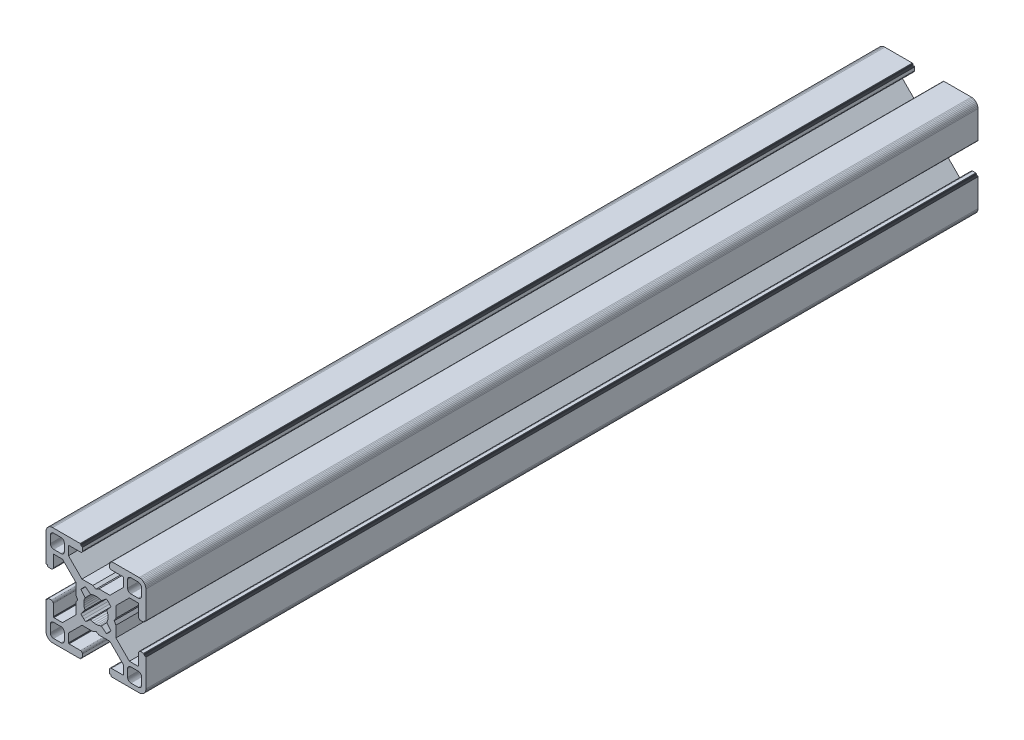
from build123d import *

# Parameters (mm, degrees)
BOSS_EXTRUDE1_DEPTH = 250


with BuildPart() as part:
    # Sketch1 → Boss-Extrude1 (new body)
    with BuildSketch(Plane.XY):
        Polygon((28.34729664, 29.969613999), (28.000000864, 29.999999329), (19.750000909, 29.999999329), (19.715268165, 29.996961355), (19.681595266, 29.987938702), (19.649999216, 29.973205179), (19.621443003, 29.953207821), (19.596790895, 29.928557575), (19.576793537, 29.899999499), (19.562061876, 29.868405312), (19.55303736, 29.834728688), (19.549999386, 29.799999669), (19.549999386, 29.699999839), (19.546961412, 29.665268958), (19.537936896, 29.631596059), (19.523203373, 29.599998146), (19.503207877, 29.571441934), (19.478557631, 29.546789825), (19.449999556, 29.526794329), (19.418403506, 29.512060806), (19.384728745, 29.503038153), (19.349999726, 29.500000179), (19.249999896, 29.500000179), (19.215267517, 29.496958527), (19.181592755, 29.487935874), (19.149996706, 29.47320235), (19.12143863, 29.453206855), (19.096788384, 29.428554746), (19.076791026, 29.399996671), (19.062057503, 29.368402484), (19.05303485, 29.334725859), (19.049996876, 29.299998703), (19.049996876, 28.39999837), (19.059110798, 28.29580945), (19.08618062, 28.194785165), (19.13038119, 28.099997016), (19.190369539, 28.014324653), (19.264324002, 27.94037019), (19.349996366, 27.88038184), (19.444784515, 27.836181271), (19.545806937, 27.809111449), (19.650010894, 27.799984574), (23.050010706, 27.799984574), (23.084741588, 27.7969466), (23.118414487, 27.787923946), (23.150012399, 27.773190423), (23.178568612, 27.753193065), (23.203220721, 27.728542819), (23.223218079, 27.699984744), (23.237949739, 27.668386831), (23.246974255, 27.634713932), (23.25001142, 27.59998608), (23.25001142, 25.049987618), (19.204474482, 20.999982084), (15.900007876, 20.999982084), (15.000008474, 20.48483404), (14.10000814, 20.999982084), (10.795543398, 20.999982084), (7.997342887, 23.801274731), (6.750011387, 25.049984589), (6.750011387, 27.599983051), (6.753049362, 27.634713932), (6.762072946, 27.668386831), (6.776805538, 27.699984744), (6.796801965, 27.728542819), (6.821454073, 27.753193065), (6.850011218, 27.773190423), (6.881607267, 27.787923946), (6.915282029, 27.7969466), (6.950011048, 27.799984574), (10.350011791, 27.799984574), (10.45420071, 27.809098497), (10.555223133, 27.836168318), (10.650011282, 27.880368888), (10.735683645, 27.940357238), (10.809638108, 28.014311701), (10.869626458, 28.099984064), (10.913827027, 28.194772213), (10.940895918, 28.295796498), (10.950010772, 28.399985417), (10.950010772, 29.299985751), (10.946974575, 29.334739239), (10.93795065, 29.368415522), (10.923215933, 29.400009153), (10.903218427, 29.428566473), (10.878566319, 29.45321765), (10.849999264, 29.473204166), (10.818403214, 29.487937689), (10.784728453, 29.496960342), (10.749999434, 29.500000179), (10.649999604, 29.500000179), (10.615270585, 29.503038153), (10.581595823, 29.512060806), (10.549999774, 29.526794329), (10.521441698, 29.546789825), (10.496791452, 29.571441934), (10.476795025, 29.599998146), (10.462061502, 29.631596059), (10.453037918, 29.665268958), (10.449999943, 29.699999839), (10.449999943, 29.799999669), (10.446961969, 29.834728688), (10.437938385, 29.868405312), (10.423205793, 29.899999499), (10.403208435, 29.928557575), (10.378557257, 29.953207821), (10.350000113, 29.973205179), (10.318404064, 29.987938702), (10.284729302, 29.996961355), (10.250000283, 29.999999329), (1.999999397, 29.999999329), (1.652702689, 29.969613999), (1.315958682, 29.879383743), (0.999999233, 29.732050374), (0.714424066, 29.532089829), (0.467910431, 29.285576195), (0.267948955, 28.999999166), (0.120614655, 28.684040532), (0.030384399, 28.34729664), (0, 28.000000864), (0, 19.750000909), (0.003037974, 19.715268165), (0.012061559, 19.681595266), (0.026795082, 19.649999216), (0.046790577, 19.621441141), (0.071442686, 19.596789032), (0.09999983, 19.576793537), (0.13159588, 19.562060013), (0.165270641, 19.55303736), (0.19999966, 19.549999386), (0.299999461, 19.549999386), (0.334728509, 19.546959549), (0.368403242, 19.537936896), (0.399999321, 19.523203373), (0.428556465, 19.503207877), (0.453208573, 19.478555769), (0.473204069, 19.449997693), (0.487937592, 19.418403506), (0.496961176, 19.384728745), (0.499999151, 19.349999726), (0.499999151, 19.249998033), (0.503038056, 19.215269014), (0.512060709, 19.181594253), (0.526794232, 19.150000066), (0.546790194, 19.121441524), (0.571441837, 19.096789882), (0.60000029, 19.076794925), (0.631595686, 19.062061999), (0.665270619, 19.053039982), (0.700000626, 19.050000801), (1.60000096, 19.050000801), (1.704189879, 19.059116587), (1.805213233, 19.086186409), (1.90000045, 19.130385115), (1.985673745, 19.190375328), (2.059627277, 19.264327928), (2.119616325, 19.350002154), (2.163816196, 19.444788441), (2.190886018, 19.545812726), (2.200000872, 19.650001645), (2.200000872, 23.050001457), (2.203039777, 23.084732338), (2.212062431, 23.118405237), (2.226795954, 23.15000315), (2.246792381, 23.178559362), (2.271443558, 23.203211471), (2.300000702, 23.223206967), (2.331596752, 23.23794049), (2.365271513, 23.246965006), (2.400001464, 23.250001117), (4.950000857, 23.250001117), (7.997332093, 20.202670812), (8.995535423, 19.204467788), (8.995535423, 15.900001182), (9.515148227, 15.00000178), (8.995535423, 14.100002378), (8.995535423, 10.795536704), (4.950000857, 6.750002138), (2.400001464, 6.750002138), (2.365271513, 6.753040112), (2.331596752, 6.762063697), (2.300000702, 6.77679722), (2.271443558, 6.796793647), (2.246792381, 6.821444824), (2.226795954, 6.850001968), (2.212062431, 6.881598018), (2.203039777, 6.915272779), (2.200000872, 6.950002729), (2.200000872, 10.350002542), (2.190896812, 10.454174265), (2.16382699, 10.555197618), (2.119627119, 10.649984836), (2.059638071, 10.735658131), (1.985684539, 10.809611663), (1.900011244, 10.869600944), (1.805224027, 10.913800582), (1.704200673, 10.940870404), (1.600011754, 10.949986189), (0.70001142, 10.949986189), (0.665281355, 10.946948596), (0.631606253, 10.937926283), (0.600010578, 10.923193954), (0.571451747, 10.903199537), (0.546799638, 10.87854836), (0.526794232, 10.850000195), (0.512060709, 10.818404146), (0.503038056, 10.784730315), (0.499999151, 10.750000365), (0.499999151, 10.650000535), (0.496961176, 10.615270585), (0.487937592, 10.581596754), (0.473204069, 10.550000705), (0.453208573, 10.521443561), (0.428556465, 10.496791452), (0.399999321, 10.476795956), (0.368403242, 10.462062433), (0.334728509, 10.453038849), (0.299999461, 10.449999943), (0.19999966, 10.449999943), (0.165270641, 10.446961969), (0.13159588, 10.437939316), (0.09999983, 10.423205793), (0.071442686, 10.403209366), (0.046790577, 10.378558189), (0.026795082, 10.350000113), (0.012061559, 10.318404064), (0.003037974, 10.284729302), (0, 10.250000283), (0, 1.999999397), (0.030384399, 1.652702689), (0.120614655, 1.315958682), (0.267948955, 0.999999233), (0.467910431, 0.714424066), (0.714424066, 0.467910431), (0.999999233, 0.267948955), (1.315958682, 0.120614655), (1.652702689, 0.030384399), (1.999999397, 0), (10.250000283, 0), (10.284729302, 0.003037974), (10.318404064, 0.012061559), (10.350000113, 0.026795082), (10.378557257, 0.046790577), (10.403208435, 0.071442686), (10.423205793, 0.09999983), (10.437938385, 0.13159588), (10.446961969, 0.165270641), (10.449999943, 0.19999966), (10.449999943, 0.300000422), (10.453037918, 0.334729441), (10.462061502, 0.368404202), (10.476795025, 0.400000252), (10.496791452, 0.428557396), (10.521441698, 0.453208573), (10.549999774, 0.473205), (10.581595823, 0.487938523), (10.615270585, 0.496961176), (10.649999604, 0.500000082), (10.749999434, 0.500000082), (10.784728453, 0.503038056), (10.818403214, 0.512060709), (10.849999264, 0.526794232), (10.878547894, 0.546800104), (10.903198606, 0.571451747), (10.923194493, 0.6000102), (10.93792742, 0.631606528), (10.946949437, 0.66528146), (10.950010772, 0.699984975), (10.950010772, 1.599985308), (10.940895918, 1.704174228), (10.913827027, 1.805197581), (10.869626458, 1.89998573), (10.809638108, 1.985658094), (10.735683645, 2.059612557), (10.650011282, 2.119600674), (10.555223133, 2.163801476), (10.45420071, 2.190870367), (10.350011791, 2.199985221), (6.950011048, 2.199985221), (6.915282029, 2.203024126), (6.881607267, 2.212046779), (6.850011218, 2.226780302), (6.821454073, 2.246776729), (6.796801965, 2.271427907), (6.776805538, 2.299985982), (6.762072946, 2.331582032), (6.753049362, 2.365256793), (6.750011387, 2.399985812), (6.750011387, 4.949985206), (9.787457566, 7.990785077), (10.795545277, 8.999985833), (14.100010019, 8.999985833), (15.000010353, 9.515133877), (15.900009756, 8.999985833), (19.204476361, 8.999985833), (20.21256413, 7.990786065), (23.25001142, 4.949988235), (23.25001142, 2.399988841), (23.246974255, 2.365256793), (23.237949739, 2.331582032), (23.223218079, 2.299985982), (23.203220721, 2.271427907), (23.178568612, 2.246776729), (23.150012399, 2.226780302), (23.118414487, 2.212046779), (23.084741588, 2.203024126), (23.050010706, 2.199985221), (19.650010894, 2.199985221), (19.545806937, 2.190883319), (19.444784515, 2.163814428), (19.349996366, 2.119613626), (19.264324002, 2.059625509), (19.190369539, 1.985671046), (19.13038119, 1.899998682), (19.08618062, 1.805210533), (19.059110798, 1.70418718), (19.049996876, 1.599998261), (19.049996876, 0.699997927), (19.053035506, 0.665268966), (19.062058795, 0.631594374), (19.076792915, 0.599998603), (19.096790813, 0.571440905), (19.121441524, 0.546790194), (19.149999978, 0.526794306), (19.181596306, 0.51206138), (19.215271238, 0.503039363), (19.249999896, 0.500000082), (19.349999726, 0.500000082), (19.384728745, 0.496961176), (19.418403506, 0.487938523), (19.449999556, 0.473205), (19.478557631, 0.453208573), (19.503207877, 0.428557396), (19.523203373, 0.400000252), (19.537936896, 0.368404202), (19.546961412, 0.334729441), (19.549999386, 0.300000422), (19.549999386, 0.19999966), (19.55303736, 0.165270641), (19.562061876, 0.13159588), (19.576793537, 0.09999983), (19.596789964, 0.071441755), (19.621442072, 0.046789646), (19.649998285, 0.02679415), (19.681594335, 0.012060627), (19.715267234, 0.003037043), (19.750000909, 0), (28.000000864, 0), (28.34729664, 0.030384399), (28.684040532, 0.120614655), (28.999999166, 0.267948955), (29.285576195, 0.467910431), (29.532089829, 0.714424066), (29.732050374, 0.999999233), (29.879383743, 1.315958682), (29.969613999, 1.652702689), (29.999999329, 1.999999397), (29.999999329, 10.250000283), (29.996974806, 10.284715361), (29.987951516, 10.318389952), (29.973217396, 10.349985723), (29.953219499, 10.378543421), (29.928568787, 10.403194133), (29.899999499, 10.423205793), (29.868405312, 10.437939316), (29.834728688, 10.446961969), (29.799999669, 10.449999943), (29.699999839, 10.449999943), (29.664909937, 10.453400043), (29.631233313, 10.462423628), (29.599637263, 10.477157151), (29.57108105, 10.497152646), (29.546427079, 10.521804755), (29.526433446, 10.550361899), (29.511699923, 10.581957949), (29.502675407, 10.615631779), (29.499637433, 10.650361729), (29.499637433, 10.750361559), (29.49697202, 10.784715548), (29.487949367, 10.818389378), (29.473215844, 10.849985428), (29.453220348, 10.878542572), (29.428568239, 10.90319468), (29.400010164, 10.923190176), (29.368415977, 10.937923699), (29.334741215, 10.946947284), (29.300012197, 10.949986189), (28.400011863, 10.949986189), (28.29581215, 10.9408876), (28.194787865, 10.913817778), (28.099999716, 10.86961814), (28.014327352, 10.809628859), (27.940374752, 10.735675327), (27.880384539, 10.650002032), (27.836185833, 10.555214814), (27.809114148, 10.454191461), (27.800000225, 10.350002542), (27.800000225, 6.950002729), (27.796962251, 6.915272779), (27.787939598, 6.881598018), (27.773206075, 6.850001968), (27.753208716, 6.821444824), (27.728558471, 6.796793647), (27.700000395, 6.77679722), (27.668404345, 6.762063697), (27.634729584, 6.753040112), (27.599998702, 6.750002138), (25.05000024, 6.750002138), (23.809199132, 7.99080223), (21.004464477, 10.795534588), (21.004464477, 14.100000262), (20.484851673, 14.999999665), (21.004464477, 15.899999067), (21.004464477, 19.204465672), (25.05000024, 23.250001117), (27.599998702, 23.250001117), (27.634729584, 23.246965006), (27.668404345, 23.23794049), (27.700000395, 23.223206967), (27.728558471, 23.203211471), (27.753208716, 23.178559362), (27.773206075, 23.15000315), (27.787939598, 23.118405237), (27.796962251, 23.084732338), (27.800000225, 23.050001457), (27.800000225, 19.650001645), (27.809114148, 19.545812726), (27.836185833, 19.444788441), (27.880384539, 19.350002154), (27.940370508, 19.264323684), (28.014323108, 19.190371084), (28.099995472, 19.130380872), (28.194783621, 19.086182165), (28.295807906, 19.059112343), (28.400001069, 19.050000801), (29.300001402, 19.050000801), (29.334730421, 19.053040638), (29.368405183, 19.062063291), (29.39999937, 19.076796814), (29.42819671, 19.097149726), (29.452848353, 19.1218023), (29.472843309, 19.150360754), (29.487576235, 19.181955219), (29.496598252, 19.215630151), (29.499637433, 19.250359227), (29.499637433, 19.35036092), (29.502675407, 19.385089939), (29.511699923, 19.4187647), (29.526433446, 19.450358887), (29.546427079, 19.478916963), (29.57108105, 19.503569071), (29.599637263, 19.523564567), (29.631233313, 19.53829809), (29.664909937, 19.547320743), (29.699999839, 19.549999386), (29.799999669, 19.549999386), (29.834728688, 19.55303736), (29.868405312, 19.562060013), (29.899999499, 19.576793537), (29.928557575, 19.596789032), (29.953207821, 19.621441141), (29.973205179, 19.649999216), (29.987938702, 19.681595266), (29.996961355, 19.715268165), (29.999999329, 19.750000909), (29.999999329, 28.000000864), (29.969613999, 28.34729664), (29.879383743, 28.684040532), (29.732050374, 28.999999166), (29.532089829, 29.285576195), (29.285576195, 29.532089829), (28.999999166, 29.732050374), (28.684040532, 29.879383743), align=None)
        Polygon((1.299998723, 25.499999523), (1.299998723, 27.699999511), (1.312309876, 27.856435627), (1.348942518, 28.009016067), (1.408992335, 28.153989464), (1.490981318, 28.287785128), (1.592892222, 28.407108039), (1.71221327, 28.50901708), (1.846008119, 28.591006994), (1.9909814, 28.651056811), (2.143563703, 28.687689453), (2.299998887, 28.699999675), (4.499998875, 28.699999675), (4.656434059, 28.687689453), (4.809016362, 28.651056811), (4.953989759, 28.591006994), (5.087784491, 28.50901708), (5.207106471, 28.407108039), (5.309016444, 28.287785128), (5.391005427, 28.153989464), (5.451056175, 28.009016067), (5.487687886, 27.856435627), (5.499999039, 27.699999511), (5.499999039, 25.499999523), (5.487687886, 25.34356527), (5.451056175, 25.190982968), (5.391005427, 25.04600957), (5.309016444, 24.912213907), (5.207106471, 24.792892858), (5.087784491, 24.690981954), (4.953989759, 24.60899204), (4.809016362, 24.548944086), (4.656434059, 24.512309581), (4.499998875, 24.499999359), (2.299998887, 24.499999359), (2.143563703, 24.512309581), (1.9909814, 24.548944086), (1.846008119, 24.60899204), (1.71221327, 24.690981954), (1.592892222, 24.792892858), (1.490981318, 24.912213907), (1.408992335, 25.04600957), (1.348942518, 25.190982968), (1.312309876, 25.34356527), align=None, mode=Mode.SUBTRACT)
        Polygon((25.34356527, 28.687689453), (25.499999523, 28.699999675), (27.699999511, 28.699999675), (27.856435627, 28.687689453), (28.009017929, 28.651056811), (28.153991327, 28.591006994), (28.28778699, 28.50901708), (28.407108039, 28.407108039), (28.50901708, 28.287785128), (28.591006994, 28.153989464), (28.651056811, 28.009016067), (28.687689453, 27.856435627), (28.700001538, 27.699999511), (28.700001538, 25.499999523), (28.687689453, 25.34356527), (28.651056811, 25.190982968), (28.591006994, 25.04600957), (28.50901708, 24.912213907), (28.407108039, 24.792892858), (28.28778699, 24.690981954), (28.153991327, 24.60899204), (28.009017929, 24.548944086), (27.856435627, 24.512309581), (27.699999511, 24.499999359), (25.499999523, 24.499999359), (25.34356527, 24.512309581), (25.190982968, 24.548944086), (25.04600957, 24.60899204), (24.912215769, 24.690981954), (24.792892858, 24.792892858), (24.690981954, 24.912213907), (24.608993903, 25.04600957), (24.548944086, 25.190982968), (24.512311444, 25.34356527), (24.500001222, 25.499999523), (24.500001222, 27.699999511), (24.512311444, 27.856435627), (24.548944086, 28.009016067), (24.608993903, 28.153989464), (24.690981954, 28.287785128), (24.792892858, 28.407108039), (24.912215769, 28.50901708), (25.04600957, 28.591006994), (25.190982968, 28.651056811), align=None, mode=Mode.SUBTRACT)
        Polygon((14.999999665, 18.649999052), (15.550030395, 18.608318642), (16.087498516, 18.484227359), (16.600128263, 18.280562013), (18.13592948, 19.518401474), (18.644984812, 19.11874488), (19.103571773, 18.662061542), (19.505336881, 18.154669553), (18.280562013, 16.600130126), (18.484227359, 16.087498516), (18.608318642, 15.550030395), (18.649999052, 14.999999665), (18.608318642, 14.449968934), (18.484227359, 13.912500814), (18.280562013, 13.399870135), (19.505336881, 11.845329776), (19.103571773, 11.337937787), (18.644984812, 10.881252587), (18.13592948, 10.481598787), (16.600128263, 11.719437316), (16.087498516, 11.515771039), (15.550030395, 11.391680688), (14.999999665, 11.349999346), (14.449968934, 11.391680688), (13.912500814, 11.515771039), (13.399870135, 11.719437316), (11.864069849, 10.481598787), (11.355013587, 10.881252587), (10.896427557, 11.337937787), (10.494662449, 11.845329776), (11.719438247, 13.399870135), (11.515771039, 13.912500814), (11.391680688, 14.449968934), (11.349999346, 14.999999665), (11.391680688, 15.550030395), (11.515771039, 16.087498516), (11.719438247, 16.600130126), (10.494662449, 18.154669553), (10.896427557, 18.662061542), (11.355013587, 19.11874488), (11.864069849, 19.518401474), (13.399870135, 18.280562013), (13.912500814, 18.484227359), (14.449968934, 18.608318642), align=None, mode=Mode.SUBTRACT)
        Polygon((4.499998875, 1.299999771), (2.299998887, 1.299999771), (2.143563703, 1.312310807), (1.9909814, 1.348942518), (1.846008119, 1.408992335), (1.71221327, 1.490982249), (1.592892222, 1.592892222), (1.490981318, 1.712214202), (1.408992335, 1.846008934), (1.348942518, 1.990982331), (1.312309876, 2.143564634), (1.299998723, 2.299998887), (1.299998723, 4.499999806), (1.312309876, 4.656434059), (1.348942518, 4.809017293), (1.408992335, 4.95399069), (1.490981318, 5.087785423), (1.592892222, 5.207106471), (1.71221327, 5.309017375), (1.846008119, 5.391006358), (1.9909814, 5.451056175), (2.143563703, 5.487688817), (2.299998887, 5.49999997), (4.499998875, 5.49999997), (4.656434059, 5.487688817), (4.809016362, 5.451056175), (4.953989759, 5.391006358), (5.087784491, 5.309017375), (5.207106471, 5.207106471), (5.309016444, 5.087785423), (5.391005427, 4.95399069), (5.451056175, 4.809017293), (5.487687886, 4.656434059), (5.499999039, 4.499999806), (5.499999039, 2.299998887), (5.487687886, 2.143564634), (5.451056175, 1.990982331), (5.391005427, 1.846008934), (5.309016444, 1.712214202), (5.207106471, 1.592892222), (5.087784491, 1.490982249), (4.953989759, 1.408992335), (4.809016362, 1.348942518), (4.656434059, 1.312310807), align=None, mode=Mode.SUBTRACT)
        Polygon((27.699999511, 1.299999771), (25.499999523, 1.299999771), (25.34356527, 1.312310807), (25.190982968, 1.348942518), (25.04600957, 1.408992335), (24.912215769, 1.490982249), (24.792892858, 1.592892222), (24.690981954, 1.712214202), (24.608993903, 1.846008934), (24.548944086, 1.990982331), (24.512311444, 2.143564634), (24.500001222, 2.299998887), (24.500001222, 4.499999806), (24.512311444, 4.656434059), (24.548944086, 4.809017293), (24.608993903, 4.95399069), (24.690981954, 5.087785423), (24.792892858, 5.207106471), (24.912215769, 5.309017375), (25.04600957, 5.391006358), (25.190982968, 5.451056175), (25.34356527, 5.487688817), (25.499999523, 5.49999997), (27.699999511, 5.49999997), (27.856435627, 5.487688817), (28.009017929, 5.451056175), (28.153991327, 5.391006358), (28.28778699, 5.309017375), (28.407108039, 5.207106471), (28.50901708, 5.087785423), (28.591006994, 4.95399069), (28.651056811, 4.809017293), (28.687689453, 4.656434059), (28.700001538, 4.499999806), (28.700001538, 2.299998887), (28.687689453, 2.143564634), (28.651056811, 1.990982331), (28.591006994, 1.846008934), (28.50901708, 1.712214202), (28.407108039, 1.592892222), (28.28778699, 1.490982249), (28.153991327, 1.408992335), (28.009017929, 1.348942518), (27.856435627, 1.312310807), align=None, mode=Mode.SUBTRACT)
    extrude(amount=-BOSS_EXTRUDE1_DEPTH)


solid = part.part
